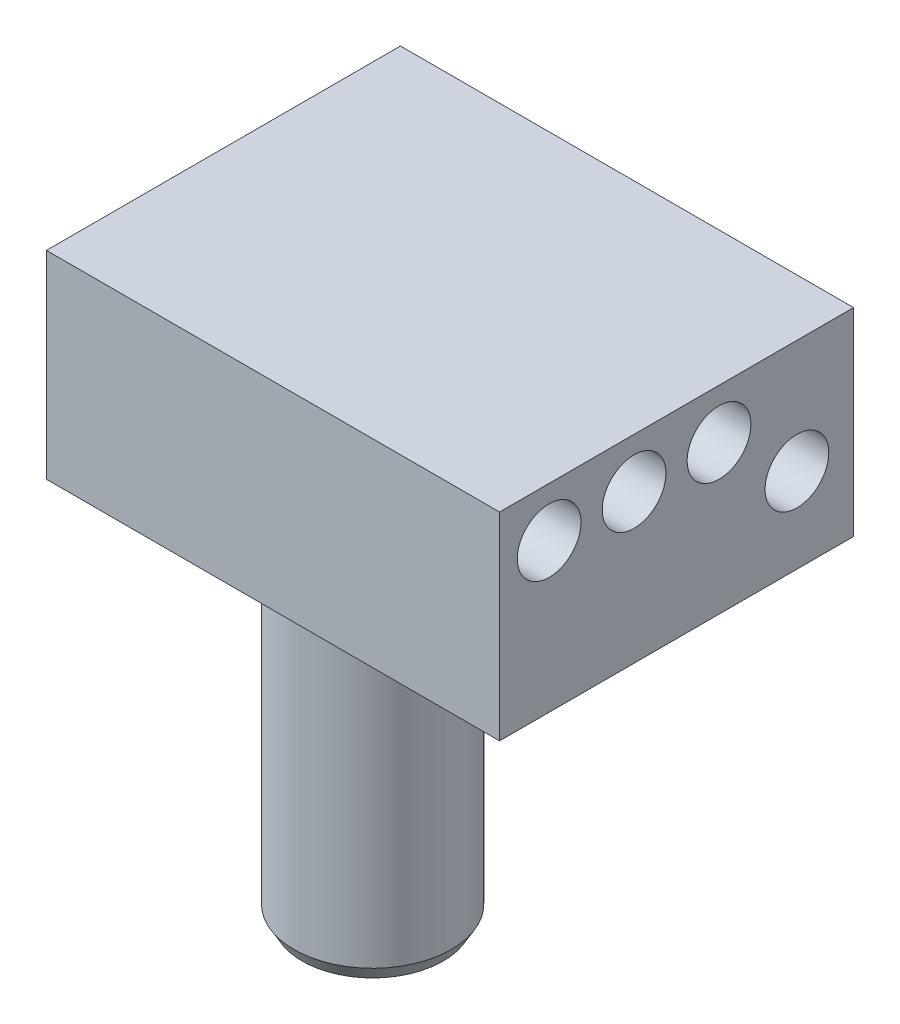
from build123d import *

# Parameters (mm, degrees)
SKETCH1_W           = 25
SKETCH1_H           = 14
SKETCH1_R           = 2.25
BOSS_EXTRUDE1_DEPTH = 20
SKETCH2_W           = 25
SKETCH2_H           = 14
BOSS_EXTRUDE2_DEPTH = 12
SKETCH3_R           = 11
BOSS_EXTRUDE3_DEPTH = 1.5
SKETCH4_R           = 10
SKETCH4_R_2         = 6.25
CUT_EXTRUDE1_DEPTH  = 1.25
SKETCH5_R           = 5.55625
BOSS_EXTRUDE4_DEPTH = 26
CHAMFER1_SIZE       = 1
CHAMFER1_SIZE2      = 0.577350269


with BuildPart() as part:
    # Sketch1 → Boss-Extrude1 (new body)
    with BuildSketch(Plane(origin=(0, 0, 0), x_dir=(0, 0, -1), z_dir=(1, 0, 0))):
        Rectangle(SKETCH1_W, SKETCH1_H)
        with Locations((8.5, -1)):
            Circle(SKETCH1_R, mode=Mode.SUBTRACT)
        with Locations((3, 3.5)):
            Circle(SKETCH1_R, mode=Mode.SUBTRACT)
        with Locations((-3, 3.5)):
            Circle(SKETCH1_R, mode=Mode.SUBTRACT)
        with Locations((-9, 3.5)):
            Circle(SKETCH1_R, mode=Mode.SUBTRACT)
    extrude(amount=BOSS_EXTRUDE1_DEPTH)

    # Sketch2 → Boss-Extrude2 (add)
    with BuildSketch(Plane.ZY):
        Rectangle(SKETCH2_W, SKETCH2_H)
    extrude(amount=BOSS_EXTRUDE2_DEPTH)

    # Sketch3 → Boss-Extrude3 (add)
    with BuildSketch(Plane.XZ.offset(7)):
        with Locations((-1, 0)):
            Circle(SKETCH3_R)
    extrude(amount=BOSS_EXTRUDE3_DEPTH)

    # Sketch4 → Cut-Extrude1 (cut)
    with BuildSketch(Plane.XZ.offset(8.5)):
        with Locations((-1, 0)):
            Circle(SKETCH4_R)
        with Locations((-1, 0.461771611)):
            Circle(SKETCH4_R_2, mode=Mode.SUBTRACT)
    extrude(amount=-CUT_EXTRUDE1_DEPTH, mode=Mode.SUBTRACT)

    # Sketch5 → Boss-Extrude4 (add)
    with BuildSketch(Plane.XZ.offset(8.5)):
        with Locations((-1, 0.461771611)):
            Circle(SKETCH5_R)
    extrude(amount=BOSS_EXTRUDE4_DEPTH)

    # Chamfer1
    chamfer1_edges = [part.edges().sort_by_distance(p)[0] for p in [
        (-6.55625, -34.5, 0.461771611),
    ]]
    chamfer1_side = [part.faces().sort_by_distance(p)[0] for p in [
        (-6.55625, -21.5, 0.461771611),
    ]]
    chamfer(chamfer1_edges, length=CHAMFER1_SIZE, length2=CHAMFER1_SIZE2, reference=chamfer1_side[0])


solid = part.part
